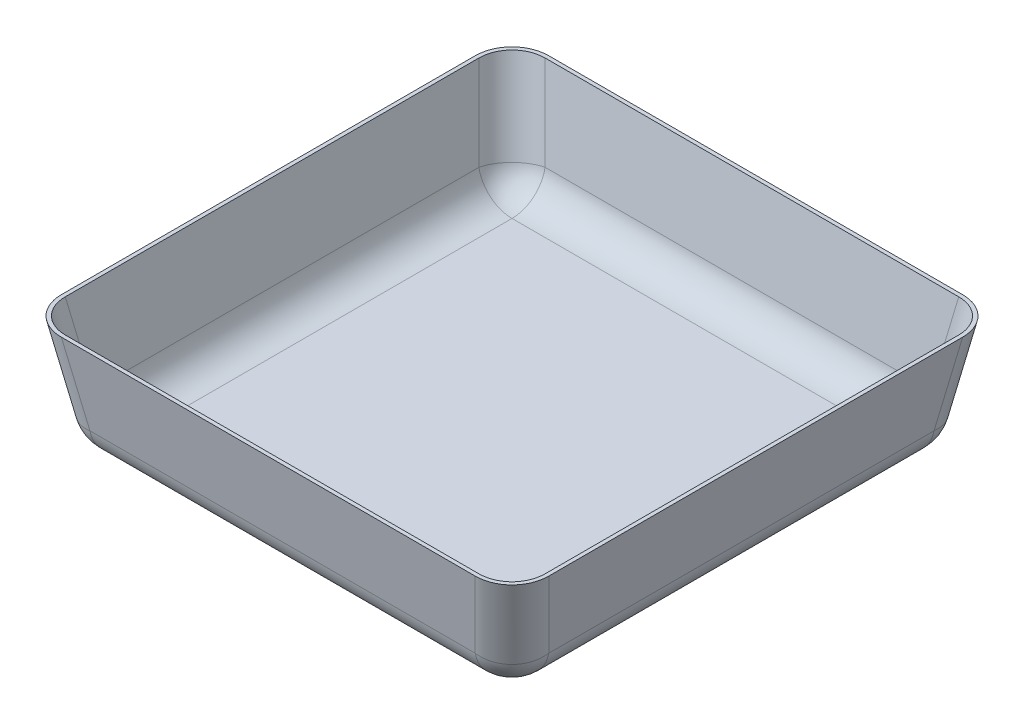
from build123d import *

# Parameters (mm, degrees)
SKETCH1_W           = 304.8
SKETCH1_H           = 304.8
BOSS_EXTRUDE1_DEPTH = 76.2
BOSS_EXTRUDE1_TAPER = -10
FILLET2_R           = 25.4
SHELL1_T            = -2.54


with BuildPart() as part:
    # Sketch1 → Boss-Extrude1 (new body)
    with BuildSketch(Plane(origin=(0, 0, 0), x_dir=(1, 0, 0), z_dir=(0, 1, 0))):
        Rectangle(SKETCH1_W, SKETCH1_H)
    extrude(amount=BOSS_EXTRUDE1_DEPTH, taper=BOSS_EXTRUDE1_TAPER)

    # Fillet2
    fillet2_edges = [part.edges().sort_by_distance(p)[0] for p in [
        (0, 0, 152.4),
        (-152.4, 0, 0),
        (0, 0, -152.4),
        (152.4, 0, 0),
        (159.118057965, 38.1, 159.118057965),
        (-159.118057965, 38.1, 159.118057965),
        (-159.118057965, 38.1, -159.118057965),
        (159.118057965, 38.1, -159.118057965),
    ]]
    fillet(fillet2_edges, radius=FILLET2_R)

    # Shell1
    shell1_openings = [part.faces().sort_by_distance(p)[0] for p in [
        (0, 76.2, 0),
    ]]
    offset(amount=SHELL1_T, openings=shell1_openings, kind=Kind.INTERSECTION)


solid = part.part
